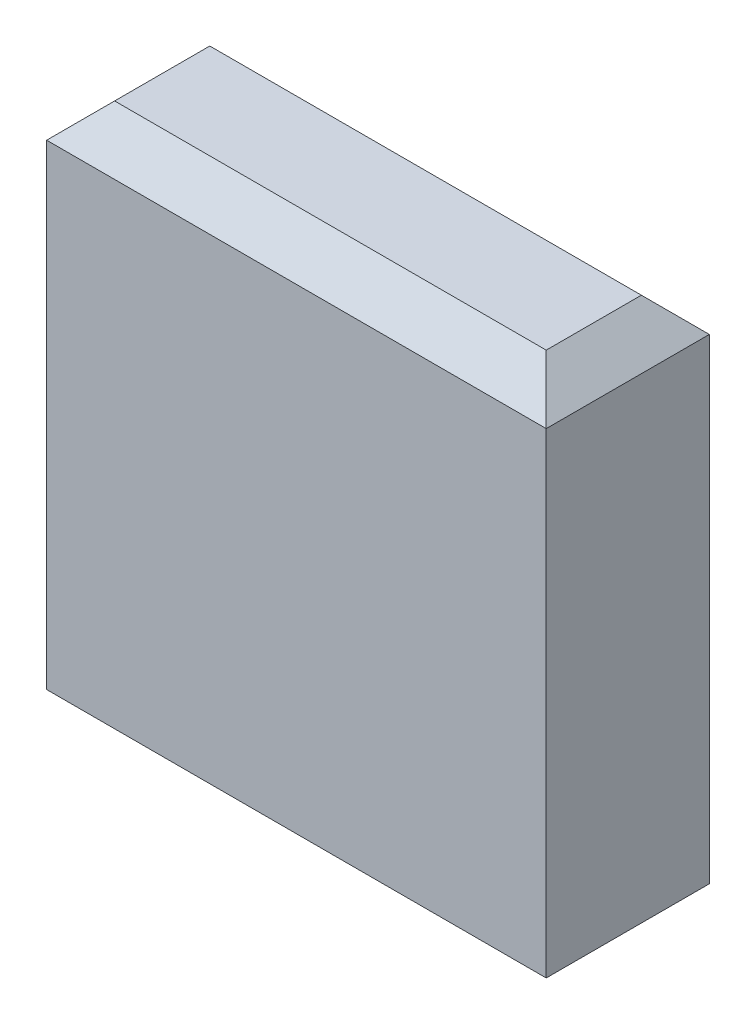
from build123d import *

# Parameters (mm, degrees)
SKETCH1_W           = 14.7
SKETCH1_H           = 4.8
BOSS_EXTRUDE1_DEPTH = 15
CHAMFER1_SIZE       = 1


with BuildPart() as part:
    # Sketch1 → Boss-Extrude1 (new body)
    with BuildSketch(Plane(origin=(0, 0, 0), x_dir=(1, 0, 0), z_dir=(0, 1, 0))):
        Rectangle(SKETCH1_W, SKETCH1_H)
    extrude(amount=BOSS_EXTRUDE1_DEPTH)

    # Chamfer1
    chamfer1_edges = [part.edges().sort_by_distance(p)[0] for p in [
        (7.35, 15, 0),
        (0, 15, -2.4),
        (-7.35, 15, 0),
        (0, 15, 2.4),
    ]]
    chamfer(chamfer1_edges, length=CHAMFER1_SIZE)


solid = part.part
